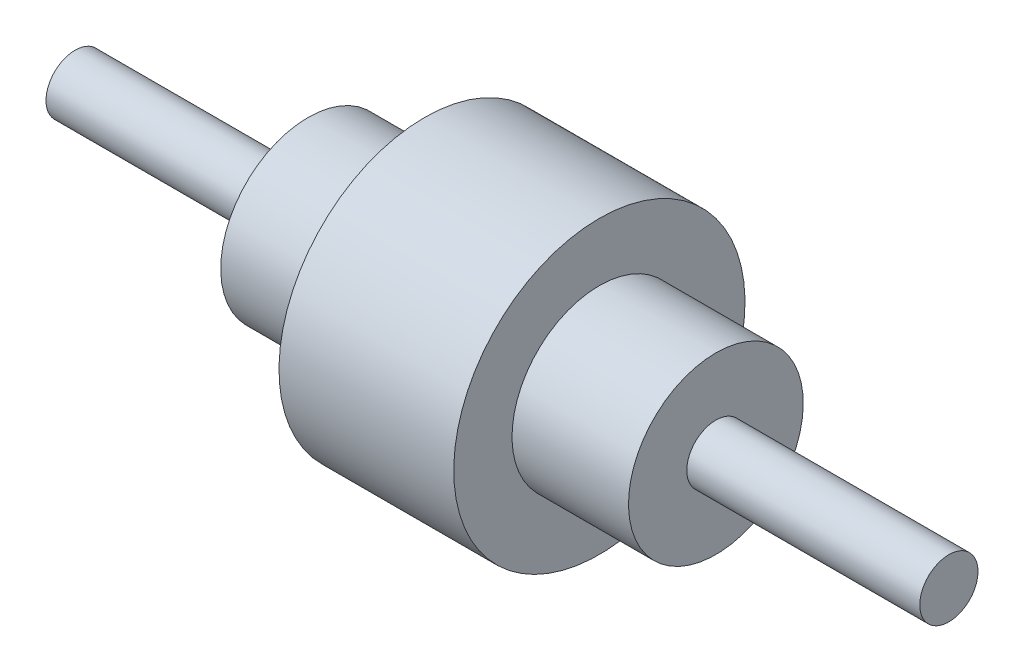
from build123d import *


with BuildPart() as part:
    # Sketch1 → Revolve1 (revolve)
    with BuildSketch(Plane.XY, mode=Mode.PRIVATE) as revolve1_sk:
        Polygon((-7620, 0), (-7620, -254), (-5588, -254), (-5588, -762), (-4572, -762), (-4572, -1270), (-3048, -1270), (-3048, -762), (-2032, -762), (-2032, -254), (0, -254), (0, 0), align=None)
    revolve(revolve1_sk.sketch.rotate(Axis((0, 0, 0), (-1, 0, 0)), 180), axis=Axis((0, 0, 0), (-1, 0, 0)))  # turned: the seam where the file's is


solid = part.part
